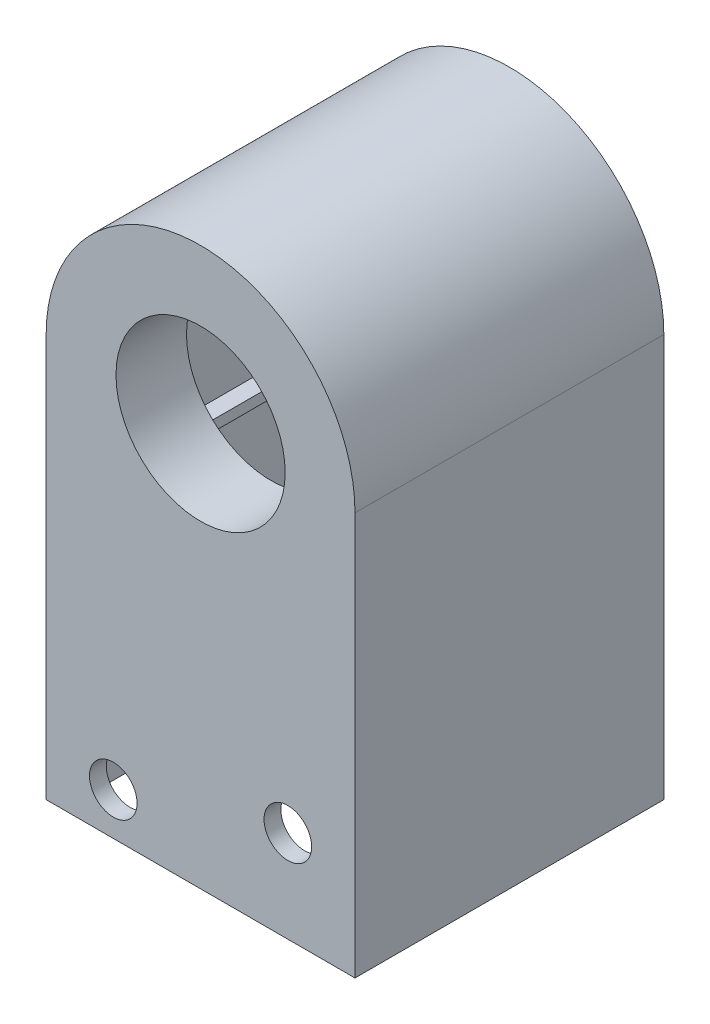
from build123d import *

# Parameters (mm, degrees)
SKETCH1_W           = 29.21
SKETCH1_H           = 29.21
SKETCH1_W_2         = 26.035
SKETCH1_H_2         = 26.035
BOSS_EXTRUDE1_DEPTH = 101.6
SKETCH2_R           = 8
CUT_EXTRUDE1_DEPTH  = 50.8
BOSS_EXTRUDE2_DEPTH = 26.035
SKETCH6_R           = 10.16
SKETCH6_R_2         = 8
BOSS_EXTRUDE3_DEPTH = 5.08
FILLET1_R           = 2.54
SKETCH7_R           = 2.25
CUT_EXTRUDE2_DEPTH  = 46.736
SKETCH8_W           = 26.035
SKETCH8_H           = 26.035
SKETCH8_W_2         = 22.86
SKETCH8_H_2         = 22.86
BOSS_EXTRUDE4_DEPTH = 1


with BuildPart() as part:
    # Sketch1 → Boss-Extrude1 (new body)
    with BuildSketch(Plane(origin=(0, 0, 0), x_dir=(1, 0, 0), z_dir=(0, 1, 0))):
        Rectangle(SKETCH1_W, SKETCH1_H)
        Rectangle(SKETCH1_W_2, SKETCH1_H_2, mode=Mode.SUBTRACT)
    extrude(amount=BOSS_EXTRUDE1_DEPTH)

    # Sketch2 → Cut-Extrude1 (cut)
    with BuildSketch(Plane.XY.offset(14.605)):
        with BuildLine():
            Line((-14.605, 101.6), (-14.605, 38.1))
            ThreePointArc((-14.605, 38.1), (0, 52.705), (14.605, 38.1))
            Line((14.605, 38.1), (14.605, 101.6))
            Line((14.605, 101.6), (-14.605, 101.6))
        make_face()
        with Locations((0, 38.1)):
            Circle(SKETCH2_R)
    extrude(amount=-CUT_EXTRUDE1_DEPTH, mode=Mode.SUBTRACT)

    # Sketch5 → Boss-Extrude2 (add)
    with BuildSketch(Plane.XY.offset(-13.0175)):
        with BuildLine():
            Line((-13.0175, 44.721987523), (-13.0175, 38.1))
            ThreePointArc((-13.0175, 38.1), (0, 51.1175), (13.0175, 38.1))
            Line((13.0175, 38.1), (13.0175, 44.721987523))
            ThreePointArc((13.0175, 44.721987523), (0, 52.705), (-13.0175, 44.721987523))
        make_face()
    extrude(amount=BOSS_EXTRUDE2_DEPTH)

    # Sketch6 → Boss-Extrude3 (add)
    with BuildSketch(Plane(origin=(0, 0, 13.0175), x_dir=(-1, 0, 0), z_dir=(0, 0, -1))):
        with Locations((0, 38.1)):
            Circle(SKETCH6_R)
        with Locations(Location((0, 38.1, 0), (0, 0, 180))):
            Circle(SKETCH6_R_2, mode=Mode.SUBTRACT)
    extrude(amount=BOSS_EXTRUDE3_DEPTH)

    # Fillet1
    fillet1_edges = [part.edges().sort_by_distance(p)[0] for p in [
        (10.16, 38.1, 13.0175),
    ]]
    fillet(fillet1_edges, radius=FILLET1_R)

    # Mirror7: part across plane


with BuildPart() as part_1:
    add(part.part)
    add(part.part.mirror(Plane.XY))

    # Sketch7 → Cut-Extrude2 (cut)
    with BuildSketch(Plane(origin=(0, 0, -14.605), x_dir=(-1, 0, 0), z_dir=(0, 0, -1))):
        with Locations((-8.255, 8.7)):
            Circle(SKETCH7_R)
        with Locations((8.255, 4)):
            Circle(SKETCH7_R)
    extrude(amount=-CUT_EXTRUDE2_DEPTH, mode=Mode.SUBTRACT)

    # Sketch8 → Boss-Extrude4 (add)
    with BuildSketch(Plane(origin=(0, 25.4, 0), x_dir=(-1, 0, 0), z_dir=(0, -1, 0))):
        Rectangle(SKETCH8_W, SKETCH8_H)
        Rectangle(SKETCH8_W_2, SKETCH8_H_2, mode=Mode.SUBTRACT)
    extrude(amount=-BOSS_EXTRUDE4_DEPTH)


solid = part_1.part
